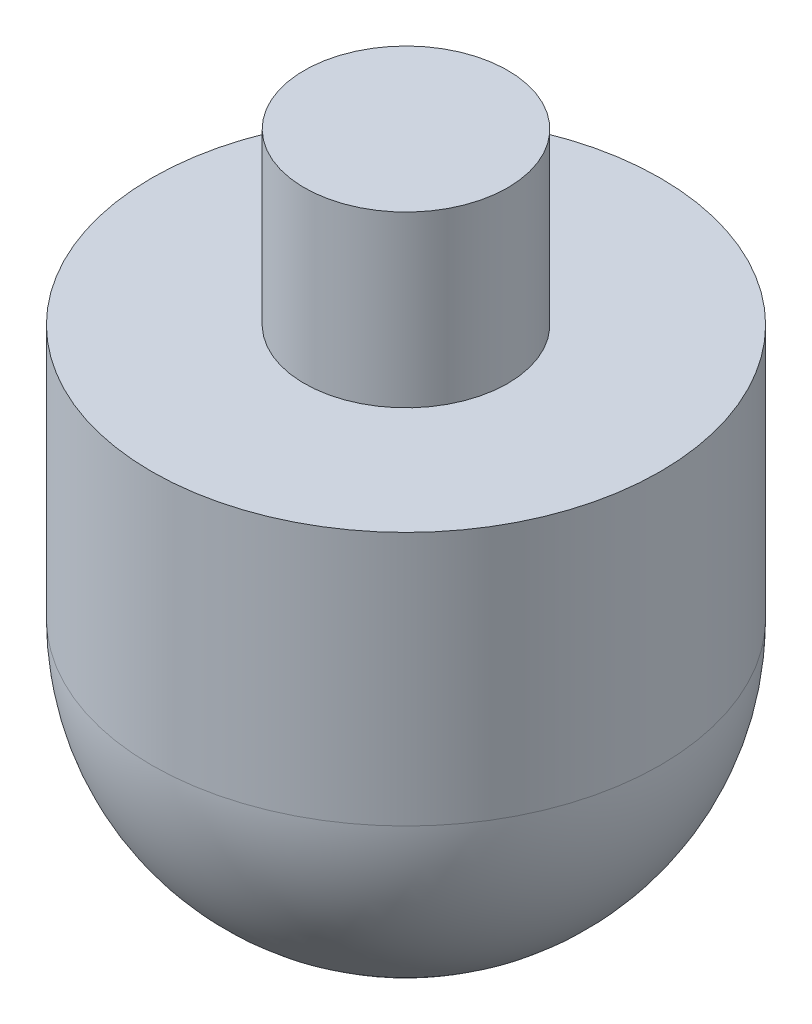
from build123d import *


with BuildPart() as part:
    # Sketch1 → Revolve2 (revolve)
    with BuildSketch(Plane.XY):
        with BuildLine():
            Line((0, 25), (0, -15))
            ThreePointArc((0, -15), (10.606601718, -10.606601718), (15, 0))
            Line((15, 0), (15, 15))
            Line((15, 15), (6, 15))
            Line((6, 15), (6, 25))
            Line((6, 25), (0, 25))
        make_face()
    revolve(axis=Axis((0, 25, 0), (0, 1, 0)))


solid = part.part
